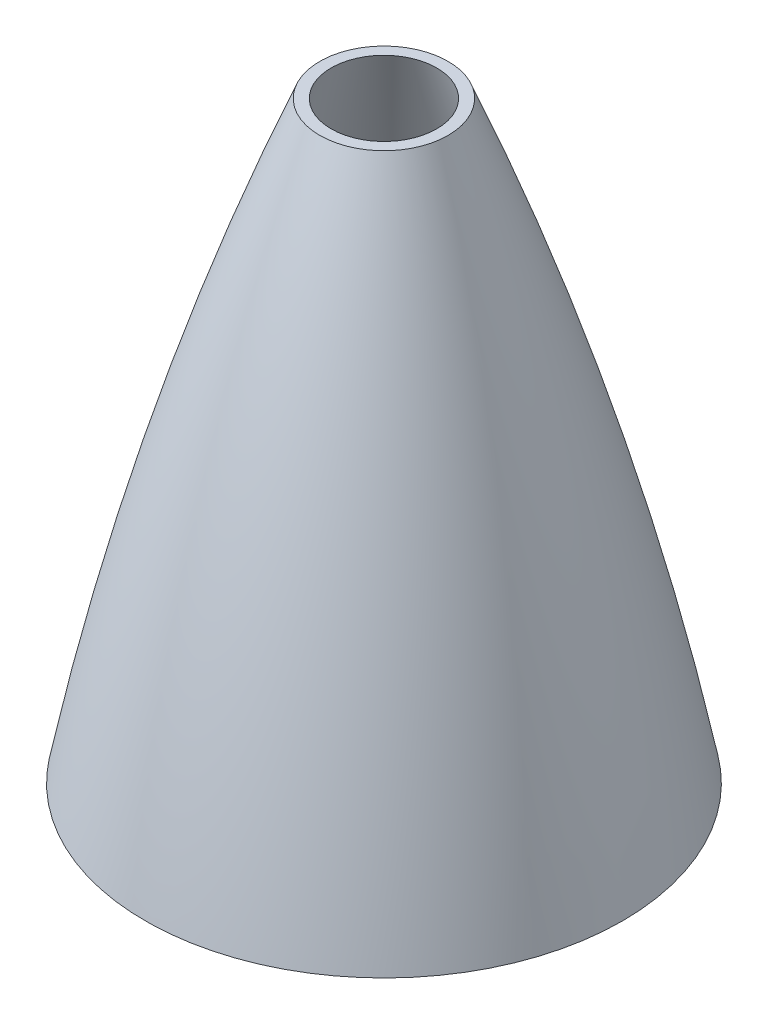
from build123d import *

# Parameters (mm, degrees)
SKETCH4_R           = 93.1545
SKETCH4_R_2         = 90.4875
BOSS_EXTRUDE2_DEPTH = 40.3999954
SKETCH7_R           = 317.5
CUT_EXTRUDE2_DEPTH  = 50.8
SKETCH8_R           = 119.216810528
CUT_EXTRUDE3_DEPTH  = 167.386


with BuildPart() as part:
    # Sketch2 → Revolve1 (revolve)
    with BuildSketch(Plane.XY):
        with BuildLine():
            Line((-98.425, 0), (-90.551, 0))
            ThreePointArc((-90.551, 0), (-60.43106349, 191.610647557), (0, 375.92))
            Line((0, 375.92), (0, 381))
            ThreePointArc((0, 381), (-66.494117829, 194.964417939), (-98.425, 0))
        make_face()
    revolve(axis=Axis((0, 381, 0), (0, -1, 0)))

    # Sketch4 → Boss-Extrude2 (add)
    with BuildSketch(Plane(origin=(0, 0, 0), x_dir=(-1, 0, 0), z_dir=(0, -1, 0))):
        Circle(SKETCH4_R)
        Circle(SKETCH4_R_2, mode=Mode.SUBTRACT)
    extrude(amount=BOSS_EXTRUDE2_DEPTH)

    # Sketch7 → Cut-Extrude2 (cut)
    with BuildSketch(Plane(origin=(0, 381, 0), x_dir=(1, 0, 0), z_dir=(0, 1, 0))):
        Circle(SKETCH7_R)
    extrude(amount=-CUT_EXTRUDE2_DEPTH, mode=Mode.SUBTRACT)

    # Sketch8 → Cut-Extrude3 (cut)
    with BuildSketch(Plane.XZ.offset(40.3999954)):
        Circle(SKETCH8_R)
    extrude(amount=-CUT_EXTRUDE3_DEPTH, mode=Mode.SUBTRACT)


solid = part.part
